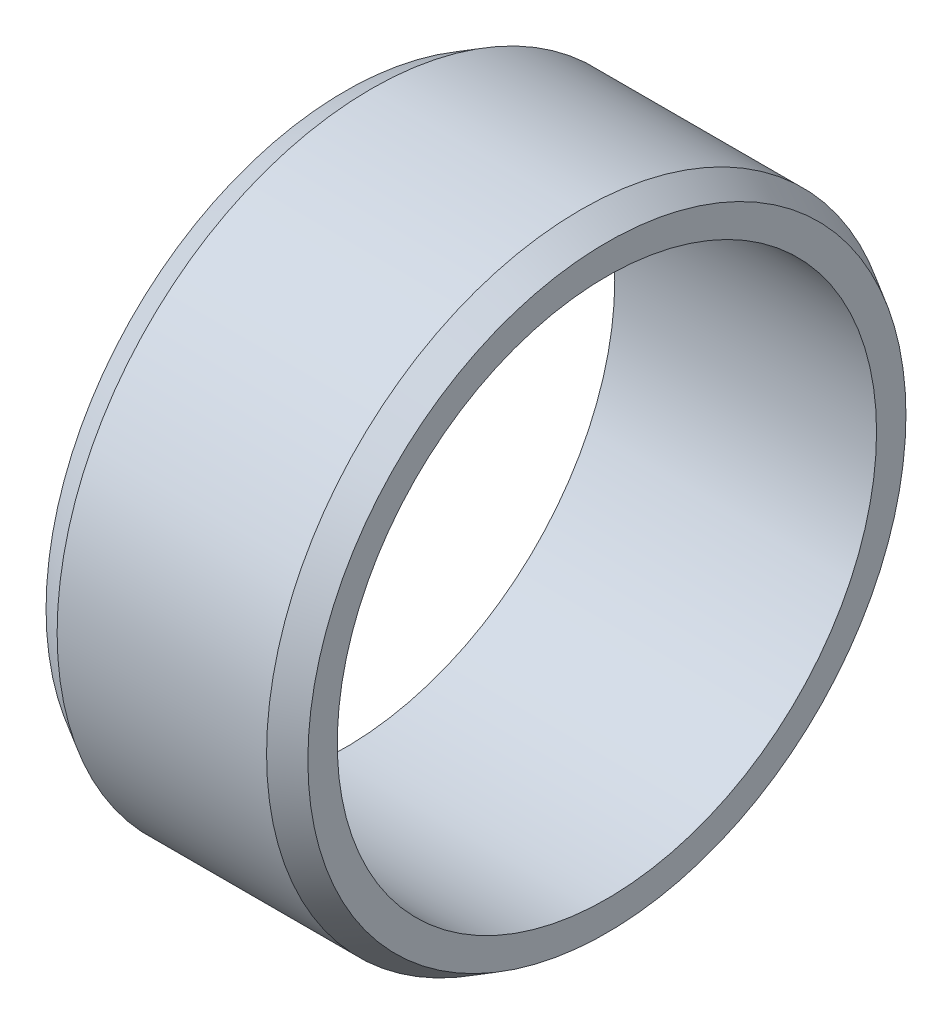
from build123d import *


with BuildPart() as part:
    # Sketch1 → Revolve1 (revolve)
    with BuildSketch(Plane.XY):
        Polygon((0, 5.15), (5, 5.15), (5, 5.711324865), (4.5, 6), (0.5, 6), (0, 5.711324865), align=None)
    revolve(axis=Axis((5, 0, 0), (-1, 0, 0)))


solid = part.part
